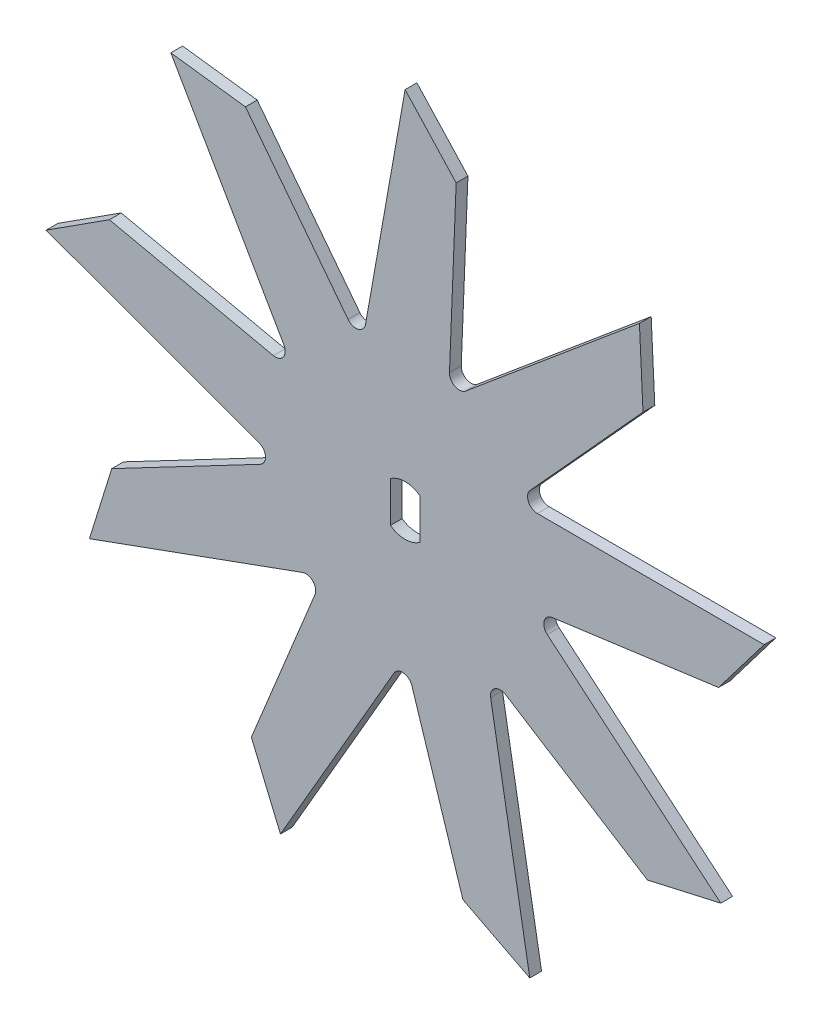
from build123d import *

# Parameters (mm, degrees)
BOSS_EXTRU_1_DEPTH = 6


with BuildPart() as part:
    # Esquisse1 → Boss.-Extru.1 (new body)
    with BuildSketch(Plane.XY):
        with BuildLine():
            Line((-20.173501956, 71.960204906), (0, 185.65))
            Line((0, 185.65), (26, 157.518641754))
            Line((26, 157.518641754), (22.59550815, 72.124873891))
            ThreePointArc((22.59550815, 72.124873891), (25.386159845, 67.438342266), (30.801329033, 68.091992195))
            Line((30.801329033, 68.091992195), (119.333519738, 142.216150865))
            Line((119.333519738, 142.216150865), (121.168186735, 103.953802351))
            Line((121.168186735, 103.953802351), (63.670138745, 40.726746182))
            ThreePointArc((63.670138745, 40.726746182), (62.795457508, 35.34285834), (67.363875848, 32.362779578))
            Line((67.363875848, 32.362779578), (182.829559347, 32.237784184))
            Line((182.829559347, 32.237784184), (159.640432263, 1.747823511))
            Line((159.640432263, 1.747823511), (74.952803807, -9.727878693))
            ThreePointArc((74.952803807, -9.727878693), (70.822062709, -13.289941795), (72.406116488, -18.509337276))
            Line((72.406116488, -18.509337276), (160.777616213, -92.825))
            Line((160.777616213, -92.825), (123.415145329, -101.275981375))
            Line((123.415145329, -101.275981375), (51.16421896, -55.630721015))
            ThreePointArc((51.16421896, -55.630721015), (45.710237669, -55.704230463), (43.568730519, -60.72072951))
            Line((43.568730519, -60.72072951), (63.496039608, -174.453935049))
            Line((63.496039608, -174.453935049), (29.442540289, -156.911629019))
            Line((29.442540289, -156.911629019), (3.435327434, -75.503330707))
            ThreePointArc((3.435327434, -75.503330707), (-0.789915589, -72.053890614), (-5.654948672, -74.520217571))
            Line((-5.654948672, -74.520217571), (-63.496039608, -174.453935049))
            Line((-63.496039608, -174.453935049), (-78.30655657, -139.126581566))
            Line((-78.30655657, -139.126581566), (-45.900991977, -60.047092835))
            ThreePointArc((-45.900991977, -60.047092835), (-46.920458564, -54.688734557), (-52.232614532, -53.45086763))
            Line((-52.232614532, -53.45086763), (-160.777616213, -92.825))
            Line((-160.777616213, -92.825), (-149.415145329, -56.242660379))
            Line((-149.415145329, -56.242660379), (-73.75972711, -16.494152877))
            ThreePointArc((-73.75972711, -16.494152877), (-71.096397514, -11.734111803), (-74.370059552, -7.371262685))
            Line((-74.370059552, -7.371262685), (-182.829559347, 32.237784184))
            Line((-182.829559347, 32.237784184), (-150.610727024, 52.957826667))
            Line((-150.610727024, 52.957826667), (-67.10546618, 34.776584525))
            ThreePointArc((-67.10546618, 34.776584525), (-62.005541919, 36.711032274), (-61.708927176, 42.157437993))
            Line((-61.708927176, 42.157437993), (-119.333519738, 142.216150865))
            Line((-119.333519738, 142.216150865), (-81.333875693, 137.378758055))
            Line((-81.333875693, 137.378758055), (-29.05181183, 69.774971528))
            ThreePointArc((-29.05181183, 69.774971528), (-23.901604145, 67.978676352), (-20.173501956, 71.960204906))
        make_face()
        with BuildLine():
            Line((-7.5, 10.310795314), (-7.5, -10.310795314))
            ThreePointArc((-7.5, -10.310795314), (0, -12.75), (7.5, -10.310795314))
            Line((7.5, -10.310795314), (7.5, 10.310795314))
            ThreePointArc((7.5, 10.310795314), (0, 12.75), (-7.5, 10.310795314))
        make_face(mode=Mode.SUBTRACT)
    extrude(amount=BOSS_EXTRU_1_DEPTH)


solid = part.part
